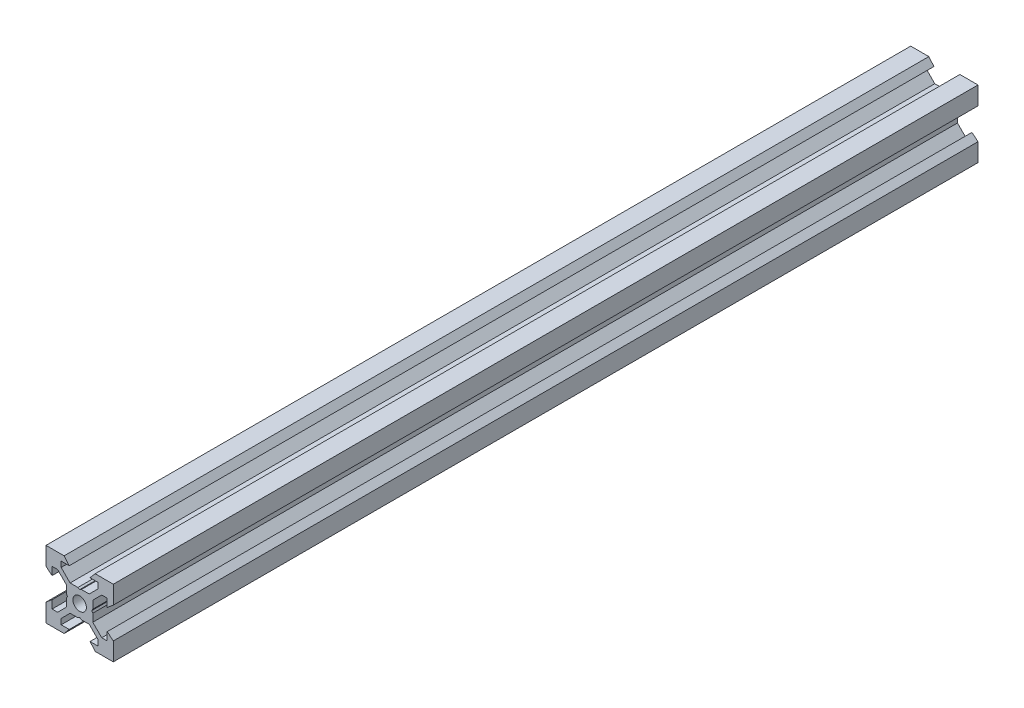
from build123d import *

# Parameters (mm, degrees)
SKETCH1_R           = 2
BOSS_EXTRUDE1_DEPTH = 128.5


with BuildPart() as part:
    # Sketch1 → Boss-Extrude1 (new body, symmetric)
    with BuildSketch(Plane.XY):
        Polygon((10, 10), (10, 4.610379336), (8.2, 3.1), (8.2, 5.5), (6.560660172, 5.5), (3.9, 2.839339828), (3.9, 0.519615242), (3.6, 0), (3.9, -0.519615242), (3.9, -2.839339828), (6.560660172, -5.5), (8.2, -5.5), (8.2, -3.1), (10, -4.610379336), (10, -10), (4.610379336, -10), (3.1, -8.2), (5.5, -8.2), (5.5, -6.560660172), (2.839339828, -3.9), (0.519615242, -3.9), (0, -3.6), (-0.519615242, -3.9), (-2.839339828, -3.9), (-5.5, -6.560660172), (-5.5, -8.2), (-3.1, -8.2), (-4.610379336, -10), (-10, -10), (-10, -4.610379336), (-8.2, -3.1), (-8.2, -5.5), (-6.560660172, -5.5), (-3.9, -2.839339828), (-3.9, -0.519615242), (-3.6, 0), (-3.9, 0.519615242), (-3.9, 2.839339828), (-6.560660172, 5.5), (-8.2, 5.5), (-8.2, 3.1), (-10, 4.610379336), (-10, 10), (-4.610379336, 10), (-3.1, 8.2), (-5.5, 8.2), (-5.5, 6.560660172), (-2.839339828, 3.9), (-0.519615242, 3.9), (0, 3.6), (0.519615242, 3.9), (2.839339828, 3.9), (5.5, 6.560660172), (5.5, 8.2), (3.1, 8.2), (4.610379336, 10), align=None)
        Circle(SKETCH1_R, mode=Mode.SUBTRACT)
    extrude(amount=BOSS_EXTRUDE1_DEPTH, both=True)


solid = part.part
